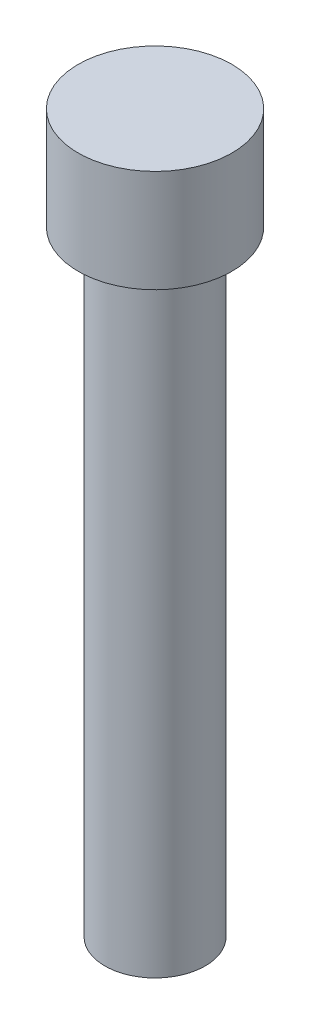
from build123d import *


with BuildPart() as part:
    # Sketch1 → Revolve1 (revolve)
    with BuildSketch(Plane.XY):
        Polygon((4.7625, 44.45), (0, 44.45), (0, 0), (3.1115, 0), (3.1115, 38.1), (4.7625, 38.1), align=None)
    revolve(axis=Axis((0, 44.45, 0), (0, -1, 0)))


solid = part.part
